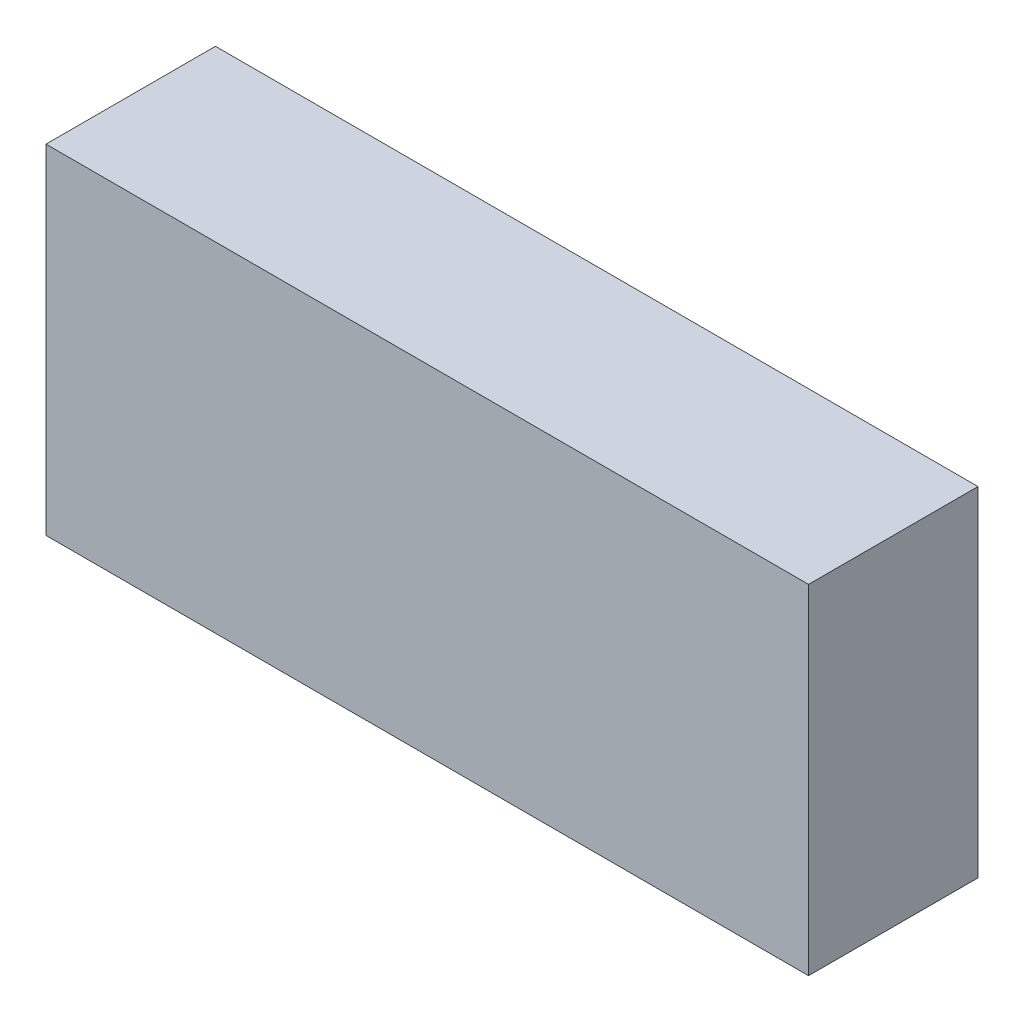
from build123d import *

# Parameters (mm, degrees)
SKETCH1_W           = 114.3
SKETCH1_H           = 50.8
BOSS_EXTRUDE1_DEPTH = 25.4


with BuildPart() as part:
    # Sketch1 → Boss-Extrude1 (new body)
    with BuildSketch(Plane.XY):
        with Locations((57.15, 25.4)):
            Rectangle(SKETCH1_W, SKETCH1_H)
    extrude(amount=BOSS_EXTRUDE1_DEPTH)


solid = part.part
